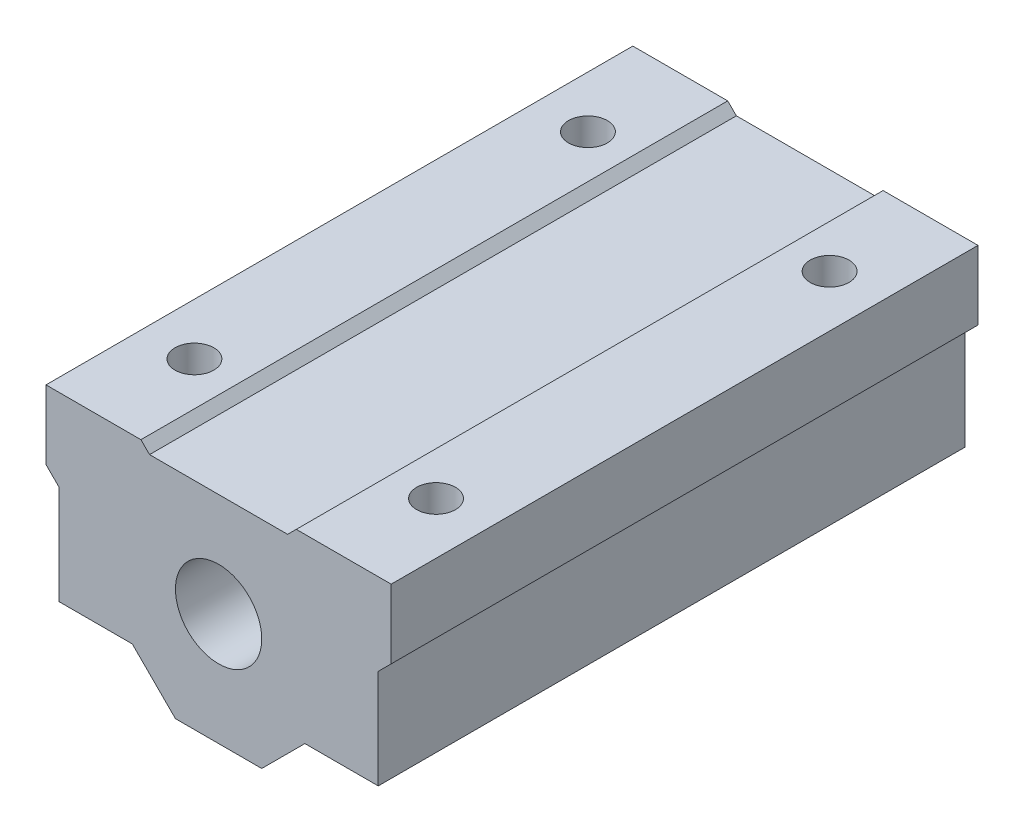
from build123d import *

# Parameters (mm, degrees)
SKETCH1_R      = 5
EXTRUDE1_DEPTH = 68
SKETCH2_R      = 2.25
EXTRUDE2_DEPTH = 68


with BuildPart() as part:
    # Sketch1 → Extrude1 (new body)
    with BuildSketch(Plane.XY):
        Polygon((-18.5, -8), (-10, -8), (-5, -13), (5, -13), (10, -8), (18.5, -8), (18.5, 3.5), (20, 5), (20, 13), (9, 13), (8, 12), (-8, 12), (-9, 13), (-20, 13), (-20, 5), (-18.5, 3.5), align=None)
        Circle(SKETCH1_R, mode=Mode.SUBTRACT)
    extrude(amount=EXTRUDE1_DEPTH)

    # Sketch2 → Extrude2 (cut)
    with BuildSketch(Plane(origin=(0, 13, 0), x_dir=(1, 0, 0), z_dir=(0, 1, 0))):
        with Locations((-14, -11.2)):
            Circle(SKETCH2_R)
        with Locations((14, -11.2)):
            Circle(SKETCH2_R)
        with Locations((14, -56.8)):
            Circle(SKETCH2_R)
        with Locations((-14, -56.8)):
            Circle(SKETCH2_R)
    extrude(amount=-EXTRUDE2_DEPTH, mode=Mode.SUBTRACT)


solid = part.part
